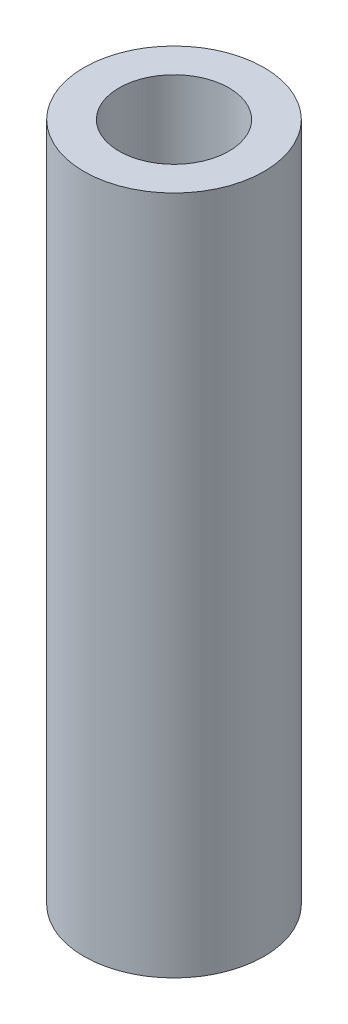
from build123d import *

# Parameters (mm, degrees)
SKETCH1_R               = 4.1
BOSS_EXTRUDE1_DEPTH     = 30.95
TAP_DRILL_FOR_M6_TAP1_D = 5


with BuildPart() as part:
    # Sketch1 → Boss-Extrude1 (new body)
    with BuildSketch(Plane(origin=(0, 0, 0), x_dir=(1, 0, 0), z_dir=(0, 1, 0))):
        with Locations((59.475545776, 35.570000001)):
            Circle(SKETCH1_R)
    extrude(amount=-BOSS_EXTRUDE1_DEPTH)

    # Tap Drill for M6 Tap1 (through all)
    with Locations(Plane(origin=(0, -30.95, 0), x_dir=(-1, 0, 0), z_dir=(0, -1, 0))):
        with Locations((-59.475545776, 35.570000001)):
            Hole(TAP_DRILL_FOR_M6_TAP1_D / 2)


solid = part.part
